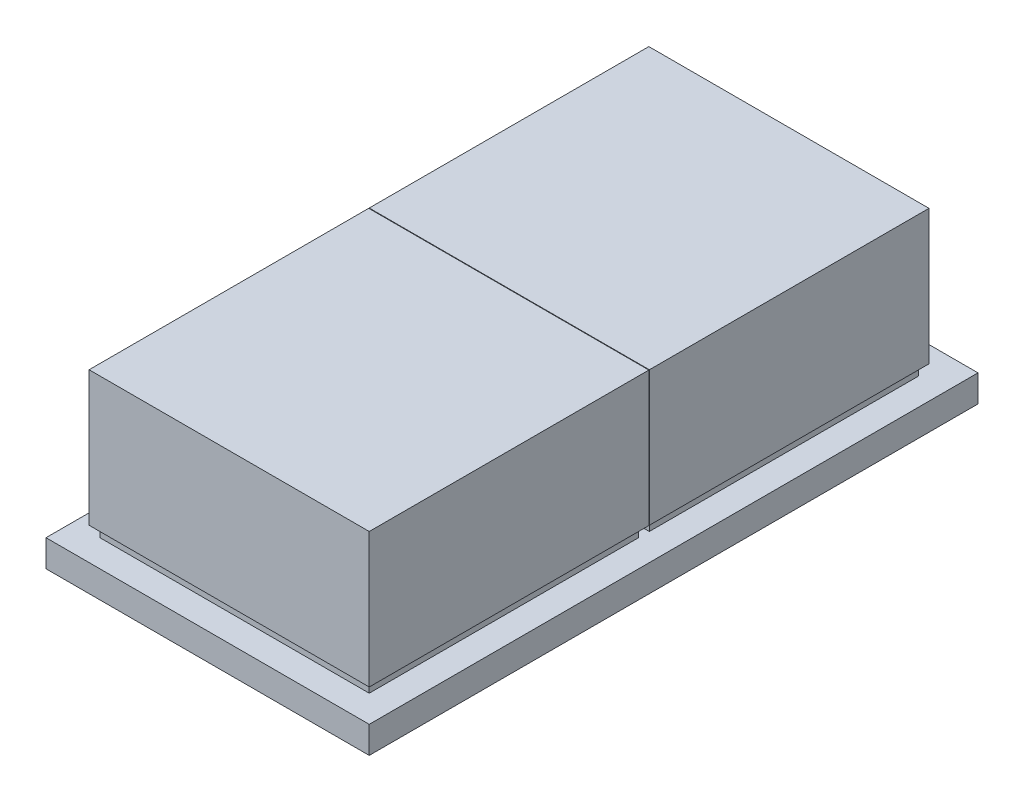
from build123d import *

# Parameters (mm, degrees)
SKETCH1_W           = 60
SKETCH1_H           = 113
BOSS_EXTRUDE1_DEPTH = 5
SKETCH2_W           = 50
SKETCH2_H           = 50
BOSS_EXTRUDE3_DEPTH = 2
LPATTERN1_COUNT     = 2
LPATTERN1_PITCH     = 52
SKETCH3_W           = 52
SKETCH3_H           = 51.9
BOSS_EXTRUDE8_DEPTH = 25
LPATTERN5_COUNT     = 2
LPATTERN5_PITCH     = 52


with BuildPart() as part:
    # Sketch1 → Boss-Extrude1 (new body)
    with BuildSketch(Plane(origin=(0, 0, 0), x_dir=(1, 0, 0), z_dir=(0, 1, 0))):
        Rectangle(SKETCH1_W, SKETCH1_H)
    extrude(amount=BOSS_EXTRUDE1_DEPTH)

    # Sketch2 → Boss-Extrude3 (add)
    with BuildSketch(Plane(origin=(0, 5, 0), x_dir=(1, 0, 0), z_dir=(0, 1, 0))):
        with Locations((0, -26.5)):
            Rectangle(SKETCH2_W, SKETCH2_H)
    boss_extrude3 = extrude(amount=BOSS_EXTRUDE3_DEPTH)

    # LPattern1: Boss-Extrude3 ×2
    with Locations(*[(0, 0, -i * LPATTERN1_PITCH) for i in range(1, LPATTERN1_COUNT)]):
        add(boss_extrude3)

    # Sketch3 → Boss-Extrude8 (add)
    with BuildSketch(Plane(origin=(0, 7, 0), x_dir=(1, 0, 0), z_dir=(0, 1, 0))):
        with Locations((0, -26.55)):
            Rectangle(SKETCH3_W, SKETCH3_H)
    boss_extrude8 = extrude(amount=BOSS_EXTRUDE8_DEPTH)

    # LPattern5: Boss-Extrude8 ×2
    with Locations(*[(0, 0, -i * LPATTERN5_PITCH) for i in range(1, LPATTERN5_COUNT)]):
        add(boss_extrude8)


solid = part.part
